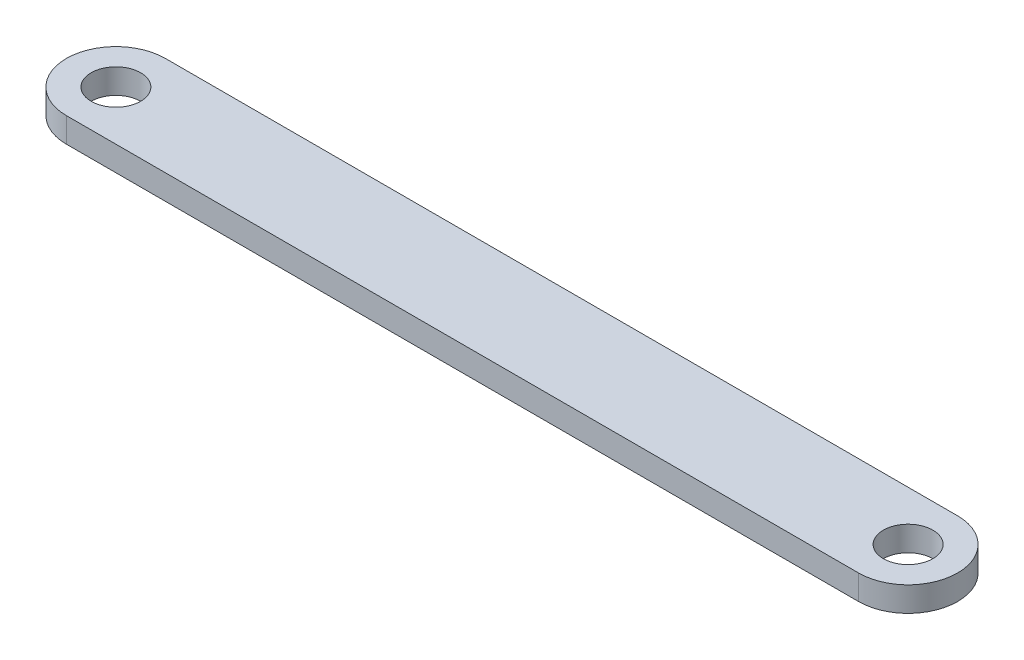
from build123d import *

# Parameters (mm, degrees)
SKETCH1_R           = 5
BOSS_EXTRUDE1_DEPTH = 5


with BuildPart() as part:
    # Sketch1 → Boss-Extrude1 (new body)
    with BuildSketch(Plane(origin=(0, 0, 0), x_dir=(1, 0, 0), z_dir=(0, 1, 0))):
        with BuildLine():
            Line((-80, 10), (80, 10))
            ThreePointArc((80, 10), (90, 0), (80, -10))
            Line((80, -10), (-80, -10))
            ThreePointArc((-80, -10), (-90, 0), (-80, 10))
        make_face()
        with Locations((-80, 0)):
            Circle(SKETCH1_R, mode=Mode.SUBTRACT)
        with Locations((80, 0)):
            Circle(SKETCH1_R, mode=Mode.SUBTRACT)
    extrude(amount=BOSS_EXTRUDE1_DEPTH)


solid = part.part
